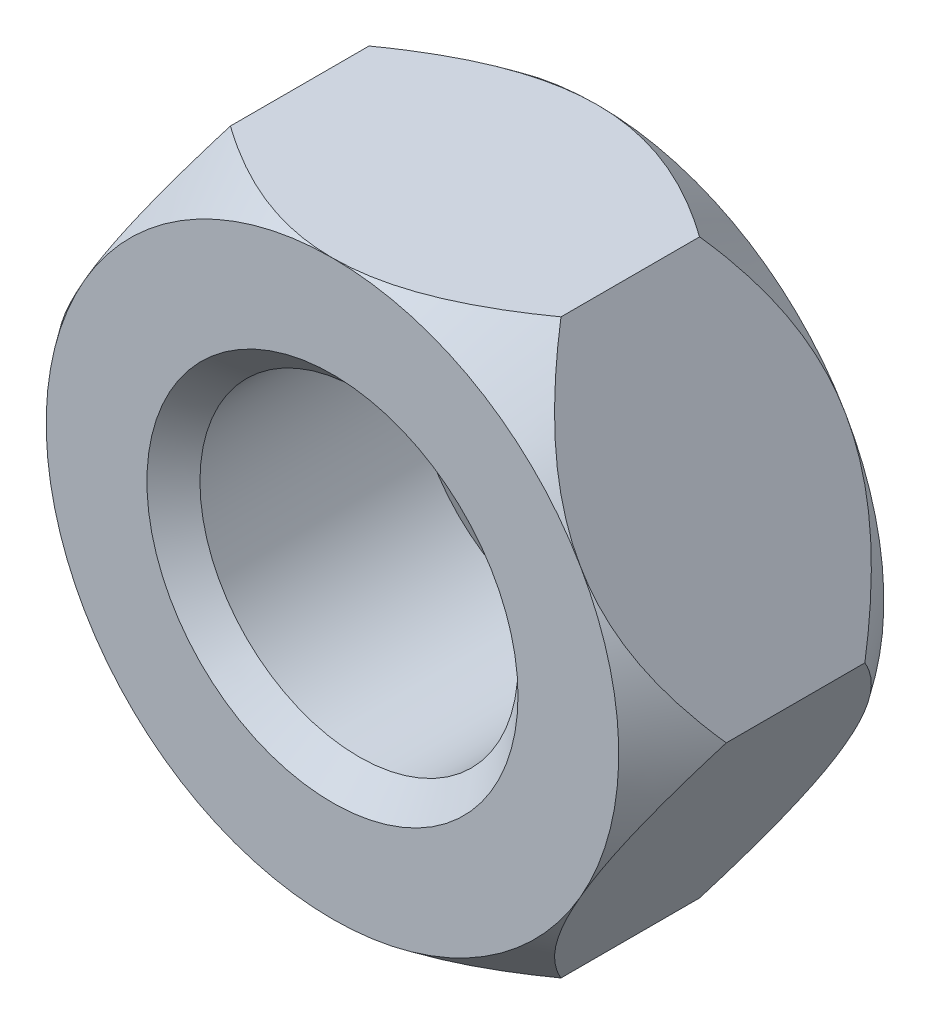
from build123d import *

# Parameters (mm, degrees)
RESSALTO_EXTRUS_O5_DEPTH        = 1.25
ESBO_O28_R                      = 1.5
CORTE_EXTRUS_O8_DEPTH           = 3.5
ESBO_O30_OUTSIDE_W              = 14.862
ESBO_O30_OUTSIDE_H              = 14.026
ESBO_O30_OUTSIDE_R              = 2.7
CORTE_EXTRUS_O9_DEPTH           = 3.5
CORTE_EXTRUS_O9_TAPER           = 35
CORTE_EXTRUS_O9_OTHER_WAY_DEPTH = 1
ESBO_O31_OUTSIDE_W              = 13.46
ESBO_O31_OUTSIDE_H              = 12.624
ESBO_O31_OUTSIDE_R              = 2.7
ESBO_O31_OUTSIDE_R_2            = 0.011999843
CORTE_EXTRUS_O10_DEPTH          = 2.5
CORTE_EXTRUS_O10_TAPER          = 35
CHANFRO3_SIZE                   = 0.25


with BuildPart() as part:
    # Esboço2 → Ressalto-extrusão5 (new body, symmetric)
    with BuildSketch(Plane.XY):
        Polygon((3.117691454, 0), (1.558845727, 2.7), (-1.558845727, 2.7), (-3.117691454, 0), (-1.558845727, -2.7), (1.558845727, -2.7), align=None)
    extrude(amount=RESSALTO_EXTRUS_O5_DEPTH, both=True)

    # Esboço28 → Corte-extrusão8 (cut, through all)
    with BuildSketch(Plane.XY.offset(1.25)):
        Circle(ESBO_O28_R)
    extrude(amount=-CORTE_EXTRUS_O8_DEPTH, mode=Mode.SUBTRACT)

    # Esboço30 outside → Corte-extrusão9 (cut)
    with BuildSketch(Plane.XY.offset(1.25)):
        Rectangle(ESBO_O30_OUTSIDE_W, ESBO_O30_OUTSIDE_H)
        Circle(ESBO_O30_OUTSIDE_R, mode=Mode.SUBTRACT)
    extrude(amount=-CORTE_EXTRUS_O9_DEPTH, taper=CORTE_EXTRUS_O9_TAPER, mode=Mode.SUBTRACT)

    # Esboço30 outside → Corte-extrusão9 other way (cut)
    with BuildSketch(Plane.XY.offset(1.25)):
        Rectangle(ESBO_O30_OUTSIDE_W, ESBO_O30_OUTSIDE_H)
        Circle(ESBO_O30_OUTSIDE_R, mode=Mode.SUBTRACT)
    extrude(amount=CORTE_EXTRUS_O9_OTHER_WAY_DEPTH, mode=Mode.SUBTRACT)

    # Esboço31 outside → Corte-extrusão10 (cut)
    with BuildSketch(Plane(origin=(0, 0, -1.25), x_dir=(-1, 0, 0), z_dir=(0, 0, -1))):
        Rectangle(ESBO_O31_OUTSIDE_W, ESBO_O31_OUTSIDE_H)
        Circle(ESBO_O31_OUTSIDE_R, mode=Mode.SUBTRACT)
        with Locations((2.629062893, 0.890906414)):
            Circle(ESBO_O31_OUTSIDE_R_2, mode=Mode.SUBTRACT)
    extrude(amount=-CORTE_EXTRUS_O10_DEPTH, taper=CORTE_EXTRUS_O10_TAPER, mode=Mode.SUBTRACT)

    # Chanfro3
    chanfro3_edges = [part.edges().sort_by_distance(p)[0] for p in [
        (-1.5, 0, -1.25),
        (-1.5, 0, 1.25),
    ]]
    chamfer(chanfro3_edges, length=CHANFRO3_SIZE)


solid = part.part
